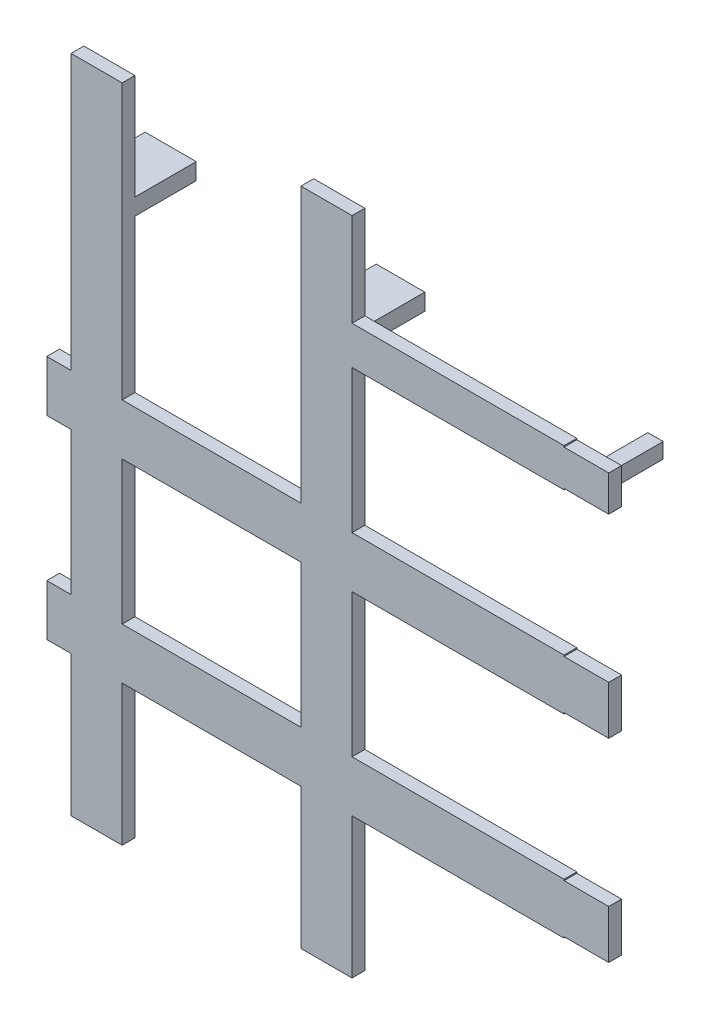
from build123d import *

# Parameters (mm, degrees)
SCHIZZO1_W                        = 4
SCHIZZO1_H                        = 51.7
ESTRUSIONE_ESTRUSIONE1_DEPTH      = 1
SCHIZZO2_W                        = 1
SCHIZZO2_H                        = 4
ESTRUSIONE_ESTRUSIONE2_DEPTH      = 18
ESTRUSIONE_ESTRUSIONE2_DEPTH_BACK = 5.9
SCHIZZO3_W                        = 1
SCHIZZO3_H                        = 4
ESTRUSIONE_ESTRUSIONE3_DEPTH      = 18
ESTRUSIONE_ESTRUSIONE3_DEPTH_BACK = 5.9
SCHIZZO4_W                        = 4
SCHIZZO4_H                        = 1
ESTRUSIONE_ESTRUSIONE4_DEPTH      = 21.5
ESTRUSIONE_ESTRUSIONE4_DEPTH_BACK = 30.2
SCHIZZO5_W                        = 1
SCHIZZO5_H                        = 3
ESTRUSIONE_ESTRUSIONE5_DEPTH      = 21
SCHIZZO7_W                        = 1
SCHIZZO7_H                        = 4
ESTRUSIONE_ESTRUSIONE6_DEPTH      = 21
SCHIZZO8_W                        = 1
SCHIZZO8_H                        = 4
ESTRUSIONE_ESTRUSIONE7_DEPTH      = 21
SCHIZZO10_W                       = 4
SCHIZZO10_H                       = 1.3
ESTRUSIONE_ESTRUSIONE9_DEPTH      = 4.8
SCHIZZO11_W                       = 3.9
SCHIZZO11_H                       = 1.3
ESTRUSIONE_ESTRUSIONE10_DEPTH     = 4.8
SCHIZZO12_W                       = 1.2
SCHIZZO12_H                       = 1.2
ESTRUSIONE_ESTRUSIONE11_DEPTH     = 4
SCHIZZO13_W                       = 1
SCHIZZO13_H                       = 4
TAGLIO_ESTRUSIONE1_DEPTH          = 0.9
SCHIZZO14_W                       = 1
SCHIZZO14_H                       = 4
TAGLIO_ESTRUSIONE2_DEPTH          = 0.9
SCHIZZO15_W                       = 1
SCHIZZO15_H                       = 3
TAGLIO_ESTRUSIONE3_DEPTH          = 0.9
SCHIZZO16_W                       = 3.503631624
SCHIZZO16_H                       = 1
TAGLIO_ESTRUSIONE4_DEPTH          = 0.1
SCHIZZO17_W                       = 3.5
SCHIZZO17_H                       = 1
TAGLIO_ESTRUSIONE5_DEPTH          = 0.1
SCHIZZO18_W                       = 3.5
SCHIZZO18_H                       = 1
TAGLIO_ESTRUSIONE6_DEPTH          = 0.1
SCHIZZO19_W                       = 3.5
SCHIZZO19_H                       = 1
TAGLIO_ESTRUSIONE7_DEPTH          = 0.1
SCHIZZO20_W                       = 3.5
SCHIZZO20_H                       = 1
TAGLIO_ESTRUSIONE8_DEPTH          = 0.1
SCHIZZO21_W                       = 3.5
SCHIZZO21_H                       = 1
TAGLIO_ESTRUSIONE9_DEPTH          = 0.1
SCHIZZO22_W                       = 0.098173234
SCHIZZO22_H                       = 1.3
TAGLIO_ESTRUSIONE10_DEPTH         = 4.8


with BuildPart() as part:
    # Schizzo1 → Estrusione-Estrusione1 (new body)
    with BuildSketch(Plane.XY):
        with Locations((2, 25.85)):
            Rectangle(SCHIZZO1_W, SCHIZZO1_H)
    extrude(amount=ESTRUSIONE_ESTRUSIONE1_DEPTH)

    # Schizzo2 → Estrusione-Estrusione2 (add, two sides)
    with BuildSketch(Plane(origin=(4, 0, 0), x_dir=(0, 0, -1), z_dir=(1, 0, 0))) as estrusione_estrusione2_sk:
        with Locations((-0.5, 28.2)):
            Rectangle(SCHIZZO2_W, SCHIZZO2_H)
    extrude(amount=ESTRUSIONE_ESTRUSIONE2_DEPTH)
    extrude(estrusione_estrusione2_sk.sketch, amount=-ESTRUSIONE_ESTRUSIONE2_DEPTH_BACK)

    # Schizzo3 → Estrusione-Estrusione3 (add, two sides)
    with BuildSketch(Plane(origin=(4, 0, 0), x_dir=(0, 0, -1), z_dir=(1, 0, 0))) as estrusione_estrusione3_sk:
        with Locations((-0.5, 13)):
            Rectangle(SCHIZZO3_W, SCHIZZO3_H)
    extrude(amount=ESTRUSIONE_ESTRUSIONE3_DEPTH)
    extrude(estrusione_estrusione3_sk.sketch, amount=-ESTRUSIONE_ESTRUSIONE3_DEPTH_BACK)

    # Schizzo4 → Estrusione-Estrusione4 (add, two sides)
    with BuildSketch(Plane(origin=(0, 30.2, 0), x_dir=(1, 0, 0), z_dir=(0, 1, 0))) as estrusione_estrusione4_sk:
        with Locations((20, -0.5)):
            Rectangle(SCHIZZO4_W, SCHIZZO4_H)
    extrude(amount=ESTRUSIONE_ESTRUSIONE4_DEPTH)
    extrude(estrusione_estrusione4_sk.sketch, amount=-ESTRUSIONE_ESTRUSIONE4_DEPTH_BACK)

    # Schizzo5 → Estrusione-Estrusione5 (add)
    with BuildSketch(Plane(origin=(22, 0, 0), x_dir=(0, 0, -1), z_dir=(1, 0, 0))):
        with Locations((-0.5, 42.898738045)):
            Rectangle(SCHIZZO5_W, SCHIZZO5_H)
    extrude(amount=ESTRUSIONE_ESTRUSIONE5_DEPTH)

    # Schizzo7 → Estrusione-Estrusione6 (add)
    with BuildSketch(Plane(origin=(22, 0, 0), x_dir=(0, 0, -1), z_dir=(1, 0, 0))):
        with Locations((-0.5, 13)):
            Rectangle(SCHIZZO7_W, SCHIZZO7_H)
    extrude(amount=ESTRUSIONE_ESTRUSIONE6_DEPTH)

    # Schizzo8 → Estrusione-Estrusione7 (add)
    with BuildSketch(Plane(origin=(22, 0, 0), x_dir=(0, 0, -1), z_dir=(1, 0, 0))):
        with Locations((-0.5, 28.2)):
            Rectangle(SCHIZZO8_W, SCHIZZO8_H)
    extrude(amount=ESTRUSIONE_ESTRUSIONE7_DEPTH)

    # Schizzo10 → Estrusione-Estrusione9 (add)
    with BuildSketch(Plane(origin=(0, 0, 0), x_dir=(-1, 0, 0), z_dir=(0, 0, -1))):
        with Locations((-2, 42.81)):
            Rectangle(SCHIZZO10_W, SCHIZZO10_H)
    extrude(amount=ESTRUSIONE_ESTRUSIONE9_DEPTH)

    # Schizzo11 → Estrusione-Estrusione10 (add)
    with BuildSketch(Plane(origin=(0, 0, 0), x_dir=(-1, 0, 0), z_dir=(0, 0, -1))):
        with Locations((-19.95, 42.91)):
            Rectangle(SCHIZZO11_W, SCHIZZO11_H)
    extrude(amount=ESTRUSIONE_ESTRUSIONE10_DEPTH)

    # Schizzo12 → Estrusione-Estrusione11 (add)
    with BuildSketch(Plane(origin=(0, 0, 0), x_dir=(-1, 0, 0), z_dir=(0, 0, -1))):
        with Locations((-40.765421969, 42.965995875)):
            Rectangle(SCHIZZO12_W, SCHIZZO12_H)
    extrude(amount=ESTRUSIONE_ESTRUSIONE11_DEPTH)

    # Schizzo13 → Taglio-Estrusione1 (cut)
    with BuildSketch(Plane(origin=(43, 0, 0), x_dir=(0, 0, -1), z_dir=(1, 0, 0))):
        with Locations((-0.5, 28.2)):
            Rectangle(SCHIZZO13_W, SCHIZZO13_H)
    extrude(amount=-TAGLIO_ESTRUSIONE1_DEPTH, mode=Mode.SUBTRACT)

    # Schizzo14 → Taglio-Estrusione2 (cut)
    with BuildSketch(Plane(origin=(43, 0, 0), x_dir=(0, 0, -1), z_dir=(1, 0, 0))):
        with Locations((-0.5, 13)):
            Rectangle(SCHIZZO14_W, SCHIZZO14_H)
    extrude(amount=-TAGLIO_ESTRUSIONE2_DEPTH, mode=Mode.SUBTRACT)

    # Schizzo15 → Taglio-Estrusione3 (cut)
    with BuildSketch(Plane(origin=(43, 0, 0), x_dir=(0, 0, -1), z_dir=(1, 0, 0))):
        with Locations((-0.5, 42.898738045)):
            Rectangle(SCHIZZO15_W, SCHIZZO15_H)
    extrude(amount=-TAGLIO_ESTRUSIONE3_DEPTH, mode=Mode.SUBTRACT)

    # Schizzo16 → Taglio-Estrusione4 (cut)
    with BuildSketch(Plane.XZ.offset(-11)):
        with Locations((40.348184188, 0.5)):
            Rectangle(SCHIZZO16_W, SCHIZZO16_H)
    extrude(amount=-TAGLIO_ESTRUSIONE4_DEPTH, mode=Mode.SUBTRACT)

    # Schizzo17 → Taglio-Estrusione5 (cut)
    with BuildSketch(Plane(origin=(0, 15, 0), x_dir=(1, 0, 0), z_dir=(0, 1, 0))):
        with Locations((40.35, -0.5)):
            Rectangle(SCHIZZO17_W, SCHIZZO17_H)
    extrude(amount=-TAGLIO_ESTRUSIONE5_DEPTH, mode=Mode.SUBTRACT)

    # Schizzo18 → Taglio-Estrusione6 (cut)
    with BuildSketch(Plane(origin=(0, 30.2, 0), x_dir=(1, 0, 0), z_dir=(0, 1, 0))):
        with Locations((40.35, -0.5)):
            Rectangle(SCHIZZO18_W, SCHIZZO18_H)
    extrude(amount=-TAGLIO_ESTRUSIONE6_DEPTH, mode=Mode.SUBTRACT)

    # Schizzo19 → Taglio-Estrusione7 (cut)
    with BuildSketch(Plane(origin=(0, 26.2, 0), x_dir=(-1, 0, 0), z_dir=(0, -1, 0))):
        with Locations((-40.35, -0.5)):
            Rectangle(SCHIZZO19_W, SCHIZZO19_H)
    extrude(amount=-TAGLIO_ESTRUSIONE7_DEPTH, mode=Mode.SUBTRACT)

    # Schizzo20 → Taglio-Estrusione8 (cut)
    with BuildSketch(Plane(origin=(0, 41.398738045, 0), x_dir=(-1, 0, 0), z_dir=(0, -1, 0))):
        with Locations((-40.35, -0.5)):
            Rectangle(SCHIZZO20_W, SCHIZZO20_H)
    extrude(amount=-TAGLIO_ESTRUSIONE8_DEPTH, mode=Mode.SUBTRACT)

    # Schizzo21 → Taglio-Estrusione9 (cut)
    with BuildSketch(Plane(origin=(0, 44.398738045, 0), x_dir=(1, 0, 0), z_dir=(0, 1, 0))):
        with Locations((40.35, -0.5)):
            Rectangle(SCHIZZO21_W, SCHIZZO21_H)
    extrude(amount=-TAGLIO_ESTRUSIONE9_DEPTH, mode=Mode.SUBTRACT)

    # Schizzo22 → Taglio-Estrusione10 (cut)
    with BuildSketch(Plane(origin=(0, 0, -4.8), x_dir=(-1, 0, 0), z_dir=(0, 0, -1))):
        with Locations((-18.049086617, 42.91)):
            Rectangle(SCHIZZO22_W, SCHIZZO22_H)
    extrude(amount=-TAGLIO_ESTRUSIONE10_DEPTH, mode=Mode.SUBTRACT)


solid = part.part
